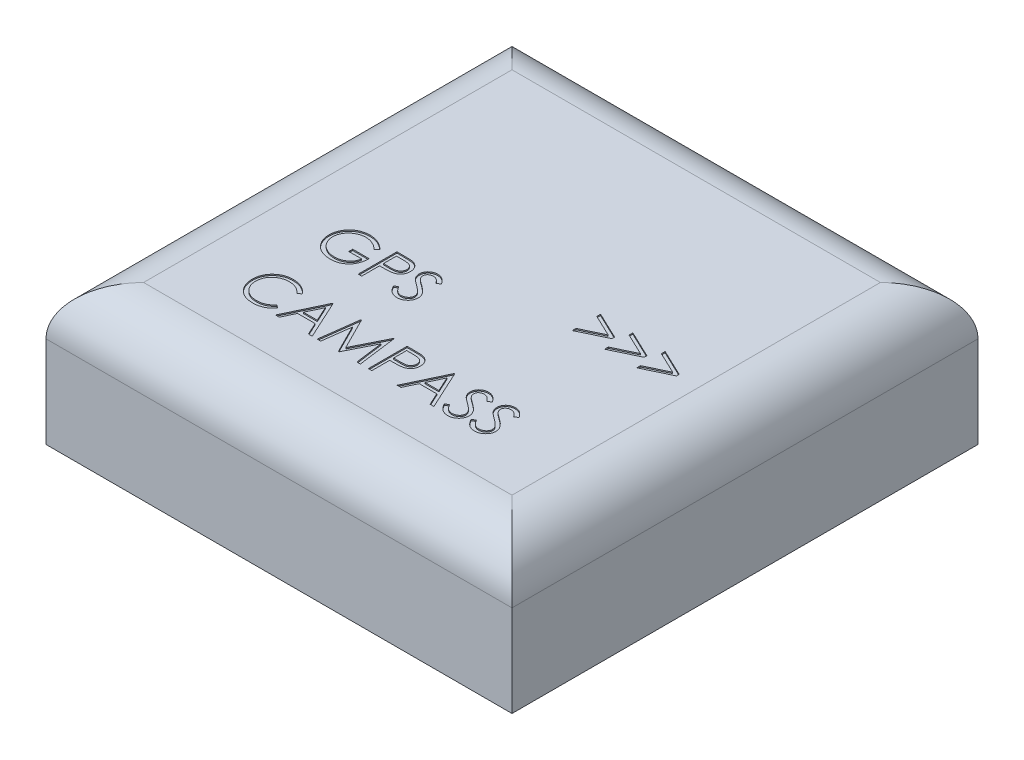
from build123d import *

# Parameters (mm, degrees)
SKETCH2_W           = 38.2
SKETCH2_H           = 38.2
BOSS_EXTRUDE1_DEPTH = 11.5
CUT_EXTRUDE1_DEPTH  = 0.1
FILLET1_R           = 4
SKETCH5_W           = 9.4
SKETCH5_H           = 4
CUT_EXTRUDE2_DEPTH  = 3


with BuildPart() as part:
    # Sketch2 → Boss-Extrude1 (new body)
    with BuildSketch(Plane(origin=(0, 0, 0), x_dir=(1, 0, 0), z_dir=(0, 1, 0))):
        Rectangle(SKETCH2_W, SKETCH2_H)
    extrude(amount=BOSS_EXTRUDE1_DEPTH)

    # Sketch4 → Cut-Extrude1 (cut)
    with BuildSketch(Plane(origin=(0, 11.5, 0), x_dir=(1, 0, 0), z_dir=(0, 1, 0))):
        Polygon((5.884704752, -0.633123186), (7.666826146, 0.217232383), (5.884704752, 1.067587952), (5.884704752, 1.377328537), (8.082781675, 0.328535468), (8.082781675, 0.105929298), (5.884704752, -0.942863771), align=None)
        Polygon((8.530538085, -0.633123186), (10.312659479, 0.217232383), (8.530538085, 1.067587952), (8.530538085, 1.377328537), (10.728615008, 0.328535468), (10.728615008, 0.105929298), (8.530538085, -0.942863771), align=None)
        Polygon((11.176371418, -0.633123186), (12.958492813, 0.217232383), (11.176371418, 1.067587952), (11.176371418, 1.377328537), (13.374448341, 0.328535468), (13.374448341, 0.105929298), (11.176371418, -0.942863771), align=None)
        with BuildLine():
            Line((-7.751098915, -3.078066088), (-7.995329685, -3.309576505))
            add(Edge.make_bspline(
                [(-7.995329685, -3.309576505), (-8.039524676, -3.268001365), (-8.126860804, -3.185842468), (-8.269246167, -3.079243208), (-8.417803178, -2.987924674), (-8.571756657, -2.913624017), (-8.72729406, -2.854339727), (-8.882350878, -2.812132057), (-9.035336621, -2.785214827), (-9.137088312, -2.781995949), (-9.18722672, -2.780409838)],
                knots=[0, 0, 0, 0, 0.000181914, 0.000359491, 0.000532492, 0.000704303, 0.000871571, 0.001031109, 0.001185858, 0.001336186, 0.001336186, 0.001336186, 0.001336186], degree=3))
            add(Edge.make_bspline(
                [(-9.18722672, -2.780409838), (-9.217992198, -2.780785038), (-9.279443362, -2.781534464), (-9.370721839, -2.791099574), (-9.461043003, -2.804856272), (-9.55023635, -2.824760689), (-9.638475303, -2.849987479), (-9.725452969, -2.881542863), (-9.811331598, -2.918332264), (-9.895302257, -2.960843222), (-9.976709714, -3.007542797), (-10.053596272, -3.059293973), (-10.126451998, -3.11443809), (-10.193907527, -3.174355764), (-10.256350875, -3.238504249), (-10.315268327, -3.305690248), (-10.368587731, -3.377749339), (-10.416749002, -3.453355728), (-10.459712756, -3.5311815), (-10.497639177, -3.610477569), (-10.52947725, -3.690980923), (-10.554668113, -3.772792579), (-10.575451349, -3.855279614), (-10.590072321, -3.939013182), (-10.598315276, -4.024082939), (-10.599741105, -4.081049024), (-10.60045789, -4.109686681)],
                knots=[0, 0, 0, 0, 9.2258e-05, 0.000184276, 0.00027504, 0.000366239, 0.000458233, 0.000550174, 0.000643626, 0.000738343, 0.000832379, 0.000924989, 0.001016197, 0.001106306, 0.001195357, 0.001284626, 0.001374178, 0.001463983, 0.001553373, 0.001640711, 0.00172752, 0.001812813, 0.001897346, 0.001982565, 0.002067558, 0.002153479, 0.002153479, 0.002153479, 0.002153479], degree=3))
            add(Edge.make_bspline(
                [(-10.60045789, -4.109686681), (-10.599772345, -4.138960922), (-10.598403128, -4.197429467), (-10.589639839, -4.284691233), (-10.573376363, -4.370656991), (-10.551634227, -4.455609226), (-10.524437345, -4.539693429), (-10.490534998, -4.622545063), (-10.450379774, -4.704161061), (-10.403900902, -4.783806042), (-10.352931989, -4.861387642), (-10.295833623, -4.934466636), (-10.235181522, -5.00401617), (-10.168766056, -5.068492042), (-10.098716899, -5.129618862), (-10.022941192, -5.185712514), (-9.94292896, -5.237853473), (-9.858558132, -5.285384602), (-9.770744179, -5.327846631), (-9.680704125, -5.365605451), (-9.588150321, -5.396701707), (-9.493569166, -5.422045558), (-9.397073413, -5.442819399), (-9.298173249, -5.456183863), (-9.197595863, -5.465881974), (-9.129797247, -5.466591061), (-9.095640181, -5.4669483)],
                knots=[0, 0, 0, 0, 8.7828e-05, 0.000175416, 0.000262738, 0.000350049, 0.000438346, 0.000527635, 0.000618372, 0.000710989, 0.000804128, 0.000896615, 0.000988996, 0.001080745, 0.001174084, 0.001267706, 0.001363321, 0.001460434, 0.001558002, 0.001655802, 0.001753148, 0.001850656, 0.00194945, 0.00204902, 0.002149905, 0.002252335, 0.002252335, 0.002252335, 0.002252335], degree=3))
            add(Edge.make_bspline(
                [(-9.095640181, -5.4669483), (-9.054475538, -5.466087806), (-8.973642072, -5.464398085), (-8.854818656, -5.451244251), (-8.740697299, -5.430700374), (-8.631598672, -5.400614168), (-8.527396061, -5.362238691), (-8.427707464, -5.315978591), (-8.333317745, -5.26005953), (-8.243943152, -5.196946093), (-8.161613419, -5.126629067), (-8.087360035, -5.050751597), (-8.022367341, -4.969681994), (-7.96566665, -4.883897743), (-7.918759513, -4.792688788), (-7.880257835, -4.696502106), (-7.850745492, -4.595294435), (-7.838630622, -4.525361312), (-7.832509172, -4.490025223)],
                knots=[0, 0, 0, 0, 0.000123468, 0.000242449, 0.000358215, 0.000471007, 0.000581478, 0.000691023, 0.000800213, 0.000910155, 0.001018877, 0.001124573, 0.001228173, 0.001330135, 0.001432542, 0.001535293, 0.001640567, 0.00174809, 0.00174809, 0.00174809, 0.00174809], degree=3))
            Line((-7.832509172, -4.490025223), (-8.890842505, -4.490025223))
            Line((-8.890842505, -4.490025223), (-8.890842505, -4.164384197))
            Line((-8.890842505, -4.164384197), (-7.547573274, -4.164384197))
            add(Edge.make_bspline(
                [(-7.547573274, -4.164384197), (-7.549120723, -4.225078848), (-7.552149358, -4.343869243), (-7.57339366, -4.51710656), (-7.607698639, -4.680729453), (-7.654561922, -4.83491024), (-7.715227355, -4.979430427), (-7.789043863, -5.114436749), (-7.877192858, -5.239057023), (-7.976534473, -5.35430862), (-8.088022292, -5.457114405), (-8.208643826, -5.54747122), (-8.338598361, -5.623582878), (-8.477762973, -5.685505051), (-8.62568208, -5.733832175), (-8.782697967, -5.768096391), (-8.948597705, -5.788625), (-9.062295976, -5.791247894), (-9.120444869, -5.792589325)],
                knots=[0, 0, 0, 0, 0.000182061, 0.000356326, 0.00052273, 0.000683073, 0.000838996, 0.000992139, 0.001143712, 0.001296104, 0.001447776, 0.00159775, 0.00174741, 0.001898587, 0.002053859, 0.002213423, 0.002380035, 0.002554445, 0.002554445, 0.002554445, 0.002554445], degree=3))
            add(Edge.make_bspline(
                [(-9.120444869, -5.792589325), (-9.156286206, -5.792073051), (-9.226976874, -5.791054792), (-9.331380788, -5.783818198), (-9.432906058, -5.772677961), (-9.531537894, -5.755854885), (-9.627639105, -5.735249449), (-9.720729728, -5.708863639), (-9.81116438, -5.678321319), (-9.899082838, -5.643581673), (-9.983687106, -5.603330241), (-10.065354018, -5.558599354), (-10.144535003, -5.509619662), (-10.220690703, -5.455544109), (-10.294217916, -5.396777163), (-10.36464254, -5.333201037), (-10.43235883, -5.265010093), (-10.47477725, -5.216587705), (-10.496150999, -5.192188684)],
                knots=[0, 0, 0, 0, 0.000107517, 0.000212058, 0.000313831, 0.000413791, 0.000512097, 0.000608547, 0.000703882, 0.000798366, 0.000891967, 0.000984756, 0.00107759, 0.00117112, 0.001264787, 0.001359809, 0.001455603, 0.001552895, 0.001552895, 0.001552895, 0.001552895], degree=3))
            add(Edge.make_bspline(
                [(-10.496150999, -5.192188684), (-10.527162523, -5.153480306), (-10.588670811, -5.076706069), (-10.667844568, -4.953697548), (-10.735337269, -4.826333004), (-10.790099507, -4.694257877), (-10.832860486, -4.557595705), (-10.863527586, -4.416521119), (-10.881495627, -4.270852454), (-10.884084193, -4.172277536), (-10.885393787, -4.122407034)],
                knots=[0, 0, 0, 0, 0.000148717, 0.000294965, 0.00043807, 0.000580636, 0.000723259, 0.000867096, 0.001013197, 0.001162796, 0.001162796, 0.001162796, 0.001162796], degree=3))
            add(Edge.make_bspline(
                [(-10.885393787, -4.122407034), (-10.884910971, -4.085063362), (-10.883951475, -4.010850633), (-10.8723169, -3.900671504), (-10.855624185, -3.792448733), (-10.831088643, -3.686270786), (-10.80015846, -3.582066749), (-10.761556369, -3.479788239), (-10.71661207, -3.379374898), (-10.664373799, -3.281517889), (-10.606240039, -3.187515743), (-10.543148054, -3.097746879), (-10.474201931, -3.013846084), (-10.400527598, -2.934750803), (-10.321246043, -2.861454706), (-10.237099994, -2.793279192), (-10.148024605, -2.730132809), (-10.053739641, -2.673010173), (-9.955652385, -2.621698889), (-9.853997955, -2.57671439), (-9.748807383, -2.539536668), (-9.640868742, -2.507991882), (-9.52936501, -2.484664576), (-9.415105344, -2.4677475), (-9.297494171, -2.456171813), (-9.217995773, -2.455240852), (-9.177686455, -2.454768813)],
                knots=[0, 0, 0, 0, 0.000111984, 0.000222545, 0.000332023, 0.000440333, 0.000549196, 0.000657879, 0.00076805, 0.000879016, 0.000990392, 0.001099448, 0.001207922, 0.001315918, 0.00142348, 0.001531553, 0.001640609, 0.001750778, 0.00186201, 0.001972503, 0.002083953, 0.002196478, 0.00230962, 0.002425384, 0.002542909, 0.002663794, 0.002663794, 0.002663794, 0.002663794], degree=3))
            add(Edge.make_bspline(
                [(-9.177686455, -2.454768813), (-9.144813192, -2.455294494), (-9.079629372, -2.45633686), (-8.982632458, -2.463561933), (-8.887134795, -2.475013597), (-8.792994784, -2.490640753), (-8.700533009, -2.511925672), (-8.609486069, -2.537396688), (-8.519721982, -2.567052841), (-8.431522071, -2.602421295), (-8.344293285, -2.642565654), (-8.257550616, -2.687753545), (-8.171590443, -2.738757656), (-8.086263695, -2.795729435), (-8.00103231, -2.857690392), (-7.917244384, -2.926412654), (-7.832877428, -2.999186154), (-7.778628639, -3.051512135), (-7.751098915, -3.078066088)],
                knots=[0, 0, 0, 0, 9.8616e-05, 0.000195543, 0.00029163, 0.000387094, 0.000481675, 0.000576117, 0.000670646, 0.000765131, 0.000861036, 0.000958613, 0.001058419, 0.001160731, 0.001266317, 0.00137439, 0.001485737, 0.001600462, 0.001600462, 0.001600462, 0.001600462], degree=3))
        make_face()
        with BuildLine():
            Line((-6.896291223, -2.536179069), (-6.273629965, -2.536179069))
            add(Edge.make_bspline(
                [(-6.273629965, -2.536179069), (-6.230802929, -2.536226146), (-6.148744425, -2.536316348), (-6.031074339, -2.539051154), (-5.924204083, -2.542703939), (-5.828364094, -2.547767513), (-5.743259491, -2.553751563), (-5.669275369, -2.562144484), (-5.6058302, -2.570907752), (-5.567815064, -2.579817171), (-5.550477922, -2.583880391)],
                knots=[0, 0, 0, 0, 0.000128477, 0.000246168, 0.000353087, 0.00044926, 0.000534089, 0.000608961, 0.000672646, 0.000726041, 0.000726041, 0.000726041, 0.000726041], degree=3))
            add(Edge.make_bspline(
                [(-5.550477922, -2.583880391), (-5.52853093, -2.589887446), (-5.485154101, -2.601760006), (-5.422651012, -2.625539598), (-5.363184309, -2.653735562), (-5.306549967, -2.685870136), (-5.253443935, -2.723322041), (-5.203073883, -2.764573108), (-5.15588433, -2.810575745), (-5.112140638, -2.860813988), (-5.071968001, -2.914444464), (-5.037378931, -2.972267773), (-5.008416375, -3.033310598), (-4.983575836, -3.09753048), (-4.965697452, -3.165466702), (-4.952229193, -3.23664722), (-4.943680617, -3.311064403), (-4.942861864, -3.361918712), (-4.942445069, -3.387806673)],
                knots=[0, 0, 0, 0, 6.8232e-05, 0.000134856, 0.000200292, 0.000265532, 0.000329934, 0.000395001, 0.000460668, 0.00052738, 0.000594672, 0.000661426, 0.000729131, 0.00079717, 0.00086768, 0.00093953, 0.001014402, 0.001092038, 0.001092038, 0.001092038, 0.001092038], degree=3))
            add(Edge.make_bspline(
                [(-4.942445069, -3.387806673), (-4.942827362, -3.413912228), (-4.943575343, -3.464989509), (-4.952552687, -3.539713395), (-4.964645075, -3.61112222), (-4.98323883, -3.67905765), (-5.007591691, -3.743116242), (-5.036159481, -3.804276931), (-5.07061597, -3.861499205), (-5.110208065, -3.914990805), (-5.154251297, -3.964801939), (-5.20255932, -4.010571646), (-5.254937106, -4.05203201), (-5.311218198, -4.089275979), (-5.371951275, -4.12143989), (-5.436215229, -4.150248302), (-5.504568639, -4.174442764), (-5.551869348, -4.187170034), (-5.575918627, -4.193641008)],
                knots=[0, 0, 0, 0, 7.8272e-05, 0.000153144, 0.000225504, 0.0002954, 0.000364034, 0.000430891, 0.000497646, 0.000564048, 0.000630282, 0.000696867, 0.000763418, 0.000830451, 0.000899029, 0.000969354, 0.001041572, 0.001116269, 0.001116269, 0.001116269, 0.001116269], degree=3))
            add(Edge.make_bspline(
                [(-5.575918627, -4.193641008), (-5.595809851, -4.197870998), (-5.639402626, -4.207141267), (-5.711196381, -4.217490367), (-5.79478541, -4.226323762), (-5.890055621, -4.232946937), (-5.996921499, -4.238616914), (-6.115440854, -4.243123685), (-6.245846338, -4.245600052), (-6.336806681, -4.245727771), (-6.384297032, -4.245794454)],
                knots=[0, 0, 0, 0, 6.0995e-05, 0.000133673, 0.000217466, 0.000313125, 0.000420129, 0.000538512, 0.000668921, 0.00081139, 0.00081139, 0.00081139, 0.00081139], degree=3))
            Line((-6.384297032, -4.245794454), (-6.611355326, -4.245794454))
            Line((-6.611355326, -4.245794454), (-6.611355326, -5.711179069))
            Line((-6.611355326, -5.711179069), (-6.896291223, -5.711179069))
            Line((-6.896291223, -5.711179069), (-6.896291223, -2.536179069))
        make_face()
        with BuildLine():
            Line((-6.611355326, -2.861820095), (-6.611355326, -3.920153428))
            Line((-6.611355326, -3.920153428), (-6.055475919, -3.927149622))
            add(Edge.make_bspline(
                [(-6.055475919, -3.927149622), (-6.028334272, -3.92716365), (-5.975937882, -3.92719073), (-5.900249308, -3.923575563), (-5.830028026, -3.919402222), (-5.765489732, -3.913291777), (-5.706605335, -3.904654637), (-5.653276648, -3.895935417), (-5.605917184, -3.883321267), (-5.550491479, -3.866336769), (-5.488730157, -3.837369324), (-5.42154031, -3.795323353), (-5.36459842, -3.74172871), (-5.315323966, -3.681469178), (-5.276220776, -3.61443211), (-5.247594983, -3.542705289), (-5.230775505, -3.467024311), (-5.228520172, -3.415237214), (-5.227380967, -3.389078708)],
                knots=[0, 0, 0, 0, 8.1413e-05, 0.000157166, 0.000227269, 0.000292454, 0.000351549, 0.000405819, 0.000454411, 0.000498462, 0.000579576, 0.00065826, 0.000735229, 0.000813005, 0.000891109, 0.000967051, 0.001043901, 0.00112234, 0.00112234, 0.00112234, 0.00112234], degree=3))
            add(Edge.make_bspline(
                [(-5.227380967, -3.389078708), (-5.228526367, -3.363553057), (-5.230803282, -3.312811221), (-5.247726815, -3.238444774), (-5.276165122, -3.167473813), (-5.315586461, -3.1012768), (-5.3634302, -3.0412341), (-5.419037461, -2.989075991), (-5.482277348, -2.947146304), (-5.541103958, -2.920083256), (-5.593356463, -2.903559399), (-5.638742598, -2.891998008), (-5.689987709, -2.882767279), (-5.747108481, -2.875292873), (-5.80966218, -2.868894376), (-5.878186223, -2.864552811), (-5.952421028, -2.86201149), (-6.003956331, -2.861885438), (-6.030671231, -2.861820095)],
                knots=[0, 0, 0, 0, 7.6536e-05, 0.000152145, 0.000227496, 0.000305051, 0.000382429, 0.000457133, 0.000532809, 0.00060908, 0.000650514, 0.0006971, 0.000749494, 0.000806611, 0.000869897, 0.000938097, 0.001012554, 0.001092695, 0.001092695, 0.001092695, 0.001092695], degree=3))
            Line((-6.030671231, -2.861820095), (-6.611355326, -2.861820095))
        make_face(mode=Mode.SUBTRACT)
        with BuildLine():
            Line((-4.616804044, -5.098694093), (-4.348404604, -4.937781633))
            add(Edge.make_bspline(
                [(-4.348404604, -4.937781633), (-4.323441632, -4.979568611), (-4.27561354, -5.059630848), (-4.195829093, -5.167814927), (-4.113158524, -5.259764884), (-4.026989628, -5.334945806), (-3.937848375, -5.394135868), (-3.845152841, -5.436047892), (-3.749215398, -5.462188099), (-3.68392486, -5.465363177), (-3.651329284, -5.4669483)],
                knots=[0, 0, 0, 0, 0.00014596, 0.000279654, 0.00040257, 0.000516191, 0.000621858, 0.000722343, 0.000820302, 0.000917964, 0.000917964, 0.000917964, 0.000917964], degree=3))
            add(Edge.make_bspline(
                [(-3.651329284, -5.4669483), (-3.623491918, -5.46617299), (-3.568304274, -5.464635936), (-3.487058525, -5.449866922), (-3.408153604, -5.427177348), (-3.333215768, -5.394682646), (-3.263279032, -5.355368448), (-3.201950101, -5.307882987), (-3.148931127, -5.254718786), (-3.105561431, -5.195407378), (-3.072287399, -5.131619679), (-3.046713165, -5.06614578), (-3.032520848, -4.997957151), (-3.030382936, -4.952046231), (-3.029304044, -4.928877386)],
                knots=[0, 0, 0, 0, 8.3437e-05, 0.000165414, 0.000246926, 0.00032927, 0.000409894, 0.000486986, 0.000561194, 0.000634468, 0.000706451, 0.000776499, 0.000844731, 0.000914244, 0.000914244, 0.000914244, 0.000914244], degree=3))
            add(Edge.make_bspline(
                [(-3.029304044, -4.928877386), (-3.030641454, -4.902442473), (-3.033360214, -4.848704156), (-3.056339485, -4.769420185), (-3.092488445, -4.690959068), (-3.125837414, -4.642425777), (-3.143151199, -4.617228748)],
                knots=[0, 0, 0, 0, 7.9176e-05, 0.000160953, 0.000245754, 0.000337316, 0.000337316, 0.000337316, 0.000337316], degree=3))
            add(Edge.make_bspline(
                [(-3.143151199, -4.617228748), (-3.157366685, -4.599043416), (-3.187210319, -4.560865584), (-3.238516062, -4.504037406), (-3.298719609, -4.445419269), (-3.365760691, -4.382772839), (-3.442081422, -4.319011766), (-3.525291381, -4.251095542), (-3.617515025, -4.181606969), (-3.682193854, -4.135004713), (-3.715567064, -4.110958716)],
                knots=[0, 0, 0, 0, 6.9232e-05, 0.000145345, 0.000229446, 0.000321262, 0.000420534, 0.000527712, 0.000643469, 0.000766871, 0.000766871, 0.000766871, 0.000766871], degree=3))
            add(Edge.make_bspline(
                [(-3.715567064, -4.110958716), (-3.74897169, -4.087165641), (-3.812838789, -4.041675091), (-3.902154789, -3.974161634), (-3.982023694, -3.912436123), (-4.052090517, -3.855917484), (-4.112324437, -3.804598049), (-4.163200102, -3.758970633), (-4.203421508, -3.71780126), (-4.225787642, -3.691093757), (-4.235829484, -3.679102747)],
                knots=[0, 0, 0, 0, 0.00012303, 0.000235223, 0.000335855, 0.000425848, 0.000505251, 0.000573234, 0.000630807, 0.000677717, 0.000677717, 0.000677717, 0.000677717], degree=3))
            add(Edge.make_bspline(
                [(-4.235829484, -3.679102747), (-4.249865293, -3.660414663), (-4.277468595, -3.623662039), (-4.3139049, -3.566217347), (-4.344873998, -3.507413385), (-4.369151256, -3.447092136), (-4.389594826, -3.386100451), (-4.403345235, -3.323642535), (-4.411955288, -3.259998645), (-4.412837018, -3.217169255), (-4.413278403, -3.195729349)],
                knots=[0, 0, 0, 0, 7.0095e-05, 0.000137851, 0.00020385, 0.000269165, 0.000332722, 0.000396603, 0.00046074, 0.000525028, 0.000525028, 0.000525028, 0.000525028], degree=3))
            add(Edge.make_bspline(
                [(-4.413278403, -3.195729349), (-4.412094392, -3.162138054), (-4.409751677, -3.095673453), (-4.389939208, -2.9985812), (-4.358667368, -2.905883521), (-4.314857006, -2.818498147), (-4.258380693, -2.738700436), (-4.193024702, -2.665572487), (-4.115181425, -2.604096702), (-4.029771545, -2.550382906), (-3.936284694, -2.508340531), (-3.838321517, -2.476625928), (-3.735726316, -2.458656101), (-3.666236329, -2.456077307), (-3.63097672, -2.454768813)],
                knots=[0, 0, 0, 0, 0.000100692, 0.000199231, 0.000295975, 0.000393537, 0.000491285, 0.000588532, 0.00068667, 0.000787797, 0.000890545, 0.00099333, 0.001096013, 0.001201783, 0.001201783, 0.001201783, 0.001201783], degree=3))
            add(Edge.make_bspline(
                [(-3.63097672, -2.454768813), (-3.593562429, -2.45605927), (-3.519157346, -2.458625578), (-3.409711271, -2.480939053), (-3.304336907, -2.517860377), (-3.219570517, -2.559760088), (-3.153228655, -2.601607872), (-3.102634819, -2.639725856), (-3.051365417, -2.68360899), (-2.999006896, -2.733374163), (-2.94644644, -2.789478002), (-2.892903737, -2.851536269), (-2.838253579, -2.919169716), (-2.803096478, -2.967451942), (-2.785073274, -2.992203708)],
                knots=[0, 0, 0, 0, 0.000112158, 0.000223046, 0.000333473, 0.000446394, 0.000505858, 0.000568569, 0.000636244, 0.000708224, 0.000785161, 0.000866773, 0.000954083, 0.001045926, 0.001045926, 0.001045926, 0.001045926], degree=3))
            Line((-2.785073274, -2.992203708), (-3.042660414, -3.18746112))
            add(Edge.make_bspline(
                [(-3.042660414, -3.18746112), (-3.058214224, -3.167423523), (-3.088167226, -3.128835794), (-3.133641832, -3.074796101), (-3.176503105, -3.02543258), (-3.218730968, -2.982556357), (-3.258095191, -2.943819422), (-3.296301365, -2.910654499), (-3.332799669, -2.882736638), (-3.378807152, -2.852942837), (-3.436608225, -2.823409437), (-3.509165626, -2.798418488), (-3.584990318, -2.783400682), (-3.636633627, -2.781415048), (-3.662777601, -2.780409838)],
                knots=[0, 0, 0, 0, 7.6089e-05, 0.000146529, 0.000211865, 0.000272136, 0.000327011, 0.000377509, 0.000423812, 0.00046474, 0.000541824, 0.000617855, 0.000694317, 0.000772712, 0.000772712, 0.000772712, 0.000772712], degree=3))
            add(Edge.make_bspline(
                [(-3.662777601, -2.780409838), (-3.695576732, -2.781509023), (-3.758826767, -2.783628698), (-3.848625052, -2.80677897), (-3.92944597, -2.843229658), (-3.998890083, -2.894315388), (-4.056708626, -2.95484086), (-4.098532864, -3.02449025), (-4.123706227, -3.101400001), (-4.126778067, -3.155049932), (-4.128342505, -3.182372979)],
                knots=[0, 0, 0, 0, 9.8196e-05, 0.000189362, 0.000276162, 0.00036267, 0.000446363, 0.000525662, 0.000604507, 0.000686336, 0.000686336, 0.000686336, 0.000686336], degree=3))
            add(Edge.make_bspline(
                [(-4.128342505, -3.182372979), (-4.127985883, -3.199383249), (-4.127272056, -3.233431604), (-4.117316347, -3.283733965), (-4.104526241, -3.333909252), (-4.084258282, -3.38373188), (-4.056277185, -3.434073192), (-4.019533204, -3.485800054), (-3.973256843, -3.539368389), (-3.93780841, -3.574209364), (-3.919092705, -3.592604349)],
                knots=[0, 0, 0, 0, 5.0945e-05, 0.000101973, 0.000153349, 0.000206142, 0.000262791, 0.000325786, 0.000396151, 0.000474855, 0.000474855, 0.000474855, 0.000474855], degree=3))
            add(Edge.make_bspline(
                [(-3.919092705, -3.592604349), (-3.912142746, -3.598806509), (-3.895631234, -3.613541419), (-3.865445216, -3.637664416), (-3.82558282, -3.667421217), (-3.777084966, -3.704239711), (-3.719057431, -3.746949323), (-3.651493833, -3.795003957), (-3.5751473, -3.849963624), (-3.520970991, -3.888387964), (-3.492324877, -3.908705111)],
                knots=[0, 0, 0, 0, 2.7941e-05, 6.6382e-05, 0.000115865, 0.000177177, 0.00024905, 0.000332006, 0.000425904, 0.000531263, 0.000531263, 0.000531263, 0.000531263], degree=3))
            add(Edge.make_bspline(
                [(-3.492324877, -3.908705111), (-3.457866227, -3.933779773), (-3.391141827, -3.98233338), (-3.296202451, -4.05528189), (-3.210120211, -4.126626651), (-3.132592876, -4.195912052), (-3.062854538, -4.262612536), (-3.001678891, -4.327530564), (-2.948442596, -4.390201048), (-2.891130019, -4.470549027), (-2.832566854, -4.569229011), (-2.782273487, -4.690131413), (-2.750561271, -4.811503789), (-2.746414254, -4.893080277), (-2.744368146, -4.93332951)],
                knots=[0, 0, 0, 0, 0.000127846, 0.000247556, 0.00035912, 0.000463173, 0.000559432, 0.00064852, 0.000730687, 0.00080588, 0.000944415, 0.001073869, 0.001197738, 0.001318375, 0.001318375, 0.001318375, 0.001318375], degree=3))
            add(Edge.make_bspline(
                [(-2.744368146, -4.93332951), (-2.744964264, -4.961794169), (-2.746144924, -5.018170725), (-2.75971661, -5.100952116), (-2.779600878, -5.181352976), (-2.809570369, -5.258379485), (-2.846149234, -5.333440806), (-2.89256433, -5.404567972), (-2.946364873, -5.473335205), (-3.008081217, -5.537908801), (-3.075614285, -5.597187136), (-3.146991637, -5.649918499), (-3.222330099, -5.693886192), (-3.301220972, -5.729764456), (-3.383682377, -5.757825576), (-3.469686581, -5.77815725), (-3.559375352, -5.790635645), (-3.620335789, -5.791930828), (-3.651329284, -5.792589325)],
                knots=[0, 0, 0, 0, 8.5312e-05, 0.000168967, 0.000251033, 0.000333365, 0.00041642, 0.000501104, 0.000587623, 0.000678047, 0.000768632, 0.000856918, 0.000943857, 0.001029813, 0.001116501, 0.001204743, 0.001294601, 0.001387538, 0.001387538, 0.001387538, 0.001387538], degree=3))
            add(Edge.make_bspline(
                [(-3.651329284, -5.792589325), (-3.675309917, -5.792125611), (-3.72296917, -5.791204021), (-3.793462772, -5.783056717), (-3.862532256, -5.771529559), (-3.929310926, -5.753228795), (-3.99465915, -5.73102468), (-4.058292713, -5.703684907), (-4.120242454, -5.670921446), (-4.180855547, -5.633460959), (-4.239977834, -5.589865719), (-4.29705478, -5.539089762), (-4.353959113, -5.482533482), (-4.409011251, -5.418661043), (-4.463324746, -5.348504353), (-4.515828732, -5.271407023), (-4.567610004, -5.187788995), (-4.60009975, -5.128947095), (-4.616804044, -5.098694093)],
                knots=[0, 0, 0, 0, 7.1915e-05, 0.000142924, 0.000212669, 0.000281785, 0.000350371, 0.000419604, 0.000489305, 0.000560431, 0.000633193, 0.000709359, 0.000789411, 0.000873714, 0.00096213, 0.001055453, 0.001153412, 0.001257074, 0.001257074, 0.001257074, 0.001257074], degree=3))
        make_face()
        with BuildLine():
            Line((-7.791804044, -9.410437883), (-8.041122954, -9.601243172))
            add(Edge.make_bspline(
                [(-8.041122954, -9.601243172), (-8.058908295, -9.580046899), (-8.094239194, -9.537940125), (-8.151080042, -9.478812967), (-8.210317961, -9.423418051), (-8.271930306, -9.371491489), (-8.337026079, -9.324849137), (-8.404028375, -9.281060351), (-8.47405803, -9.241810332), (-8.570897104, -9.194218909), (-8.697577652, -9.144556325), (-8.857048684, -9.102915537), (-9.023519467, -9.076407756), (-9.137091575, -9.073536793), (-9.194858931, -9.072076505)],
                knots=[0, 0, 0, 0, 8.299e-05, 0.000164861, 0.000245858, 0.000326233, 0.000406381, 0.000485944, 0.000566254, 0.000647036, 0.000809554, 0.000973391, 0.001140702, 0.001313896, 0.001313896, 0.001313896, 0.001313896], degree=3))
            add(Edge.make_bspline(
                [(-9.194858931, -9.072076505), (-9.226684496, -9.072442957), (-9.290040253, -9.073172459), (-9.384064226, -9.082796451), (-9.476332494, -9.096323049), (-9.566785038, -9.116393878), (-9.655306722, -9.141769039), (-9.742476258, -9.172090665), (-9.827031588, -9.209605412), (-9.910142418, -9.251069334), (-9.989770702, -9.297902802), (-10.065113496, -9.348987057), (-10.135896009, -9.403750451), (-10.202174236, -9.462398241), (-10.264015932, -9.524666305), (-10.320972993, -9.591218243), (-10.372848329, -9.661841286), (-10.420670202, -9.735604163), (-10.463498896, -9.812292017), (-10.499358143, -9.892188688), (-10.53111279, -9.973925981), (-10.55623996, -10.058427392), (-10.576128629, -10.145098329), (-10.589851581, -10.234171401), (-10.599366122, -10.325460525), (-10.600091997, -10.387336116), (-10.60045789, -10.418525824)],
                knots=[0, 0, 0, 0, 9.5437e-05, 0.000189987, 0.000283265, 0.000375086, 0.000467691, 0.000559419, 0.000651703, 0.000744998, 0.000837935, 0.000928607, 0.001017915, 0.001106228, 0.001193927, 0.001280987, 0.00136876, 0.001456615, 0.001544584, 0.001631962, 0.001719133, 0.001807466, 0.001896183, 0.00198569, 0.002077709, 0.002171238, 0.002171238, 0.002171238, 0.002171238], degree=3))
            add(Edge.make_bspline(
                [(-10.60045789, -10.418525824), (-10.59931324, -10.465453521), (-10.597065871, -10.55758983), (-10.577064882, -10.692546027), (-10.546670978, -10.821832638), (-10.501118276, -10.944641495), (-10.444948852, -11.062486934), (-10.37397344, -11.173375037), (-10.291771295, -11.278981492), (-10.1971795, -11.376810452), (-10.093397082, -11.466176474), (-9.98204719, -11.544871644), (-9.863407158, -11.610471573), (-9.738786929, -11.665059753), (-9.607227526, -11.707021213), (-9.468965526, -11.736561526), (-9.324301645, -11.755831218), (-9.225450832, -11.757676063), (-9.175142385, -11.758614966)],
                knots=[0, 0, 0, 0, 0.000140704, 0.000276253, 0.000408455, 0.000538433, 0.000668431, 0.000799358, 0.000932567, 0.001069312, 0.00120687, 0.001342915, 0.001477586, 0.00161288, 0.00175046, 0.001891054, 0.002036604, 0.002187448, 0.002187448, 0.002187448, 0.002187448], degree=3))
            add(Edge.make_bspline(
                [(-9.175142385, -11.758614966), (-9.119713517, -11.757083002), (-9.010616245, -11.754067729), (-8.85062525, -11.728523268), (-8.697467091, -11.687105014), (-8.551133531, -11.62914047), (-8.412037102, -11.553788387), (-8.279960131, -11.462441027), (-8.154791135, -11.354229468), (-8.079524329, -11.271604059), (-8.041122954, -11.2294483)],
                knots=[0, 0, 0, 0, 0.000166206, 0.000327134, 0.000484664, 0.00064139, 0.000798189, 0.000958205, 0.001122325, 0.001293282, 0.001293282, 0.001293282, 0.001293282], degree=3))
            Line((-8.041122954, -11.2294483), (-7.791804044, -11.418345535))
            add(Edge.make_bspline(
                [(-7.791804044, -11.418345535), (-7.811868329, -11.444233988), (-7.851900793, -11.49588689), (-7.916723423, -11.568704798), (-7.985010685, -11.637197744), (-8.057269794, -11.700813515), (-8.132669505, -11.760825066), (-8.212563674, -11.815527441), (-8.29590201, -11.865684172), (-8.382402145, -11.911610025), (-8.471972172, -11.952356385), (-8.564504767, -11.987239446), (-8.659601074, -12.017288452), (-8.757265443, -12.042009852), (-8.857700451, -12.061305764), (-8.960543667, -12.07420504), (-9.066017053, -12.083042349), (-9.137174628, -12.083847815), (-9.173234332, -12.084255992)],
                knots=[0, 0, 0, 0, 9.8237e-05, 0.000196004, 0.000292247, 0.000388218, 0.000484669, 0.00058117, 0.000678466, 0.000776338, 0.000874822, 0.000973456, 0.001072826, 0.001173865, 0.001275526, 0.001379423, 0.001484691, 0.001592844, 0.001592844, 0.001592844, 0.001592844], degree=3))
            add(Edge.make_bspline(
                [(-9.173234332, -12.084255992), (-9.207382516, -12.084018327), (-9.27490632, -12.083548375), (-9.374600188, -12.07593548), (-9.471655022, -12.065548933), (-9.565793432, -12.049909671), (-9.657529138, -12.031454449), (-9.746030526, -12.006715523), (-9.832168467, -11.979003065), (-9.91559689, -11.946432112), (-9.99638676, -11.909678147), (-10.074277504, -11.868138661), (-10.149233296, -11.82216297), (-10.221991071, -11.772764496), (-10.291476021, -11.718356515), (-10.358290291, -11.659694639), (-10.422808537, -11.596976587), (-10.462725259, -11.551751113), (-10.482794629, -11.529012603)],
                knots=[0, 0, 0, 0, 0.000102417, 0.000202516, 0.000299794, 0.000395154, 0.000488707, 0.000580357, 0.000670665, 0.000760075, 0.000848874, 0.000936794, 0.001024712, 0.001112565, 0.001200478, 0.001289268, 0.001379219, 0.001470177, 0.001470177, 0.001470177, 0.001470177], degree=3))
            add(Edge.make_bspline(
                [(-10.482794629, -11.529012603), (-10.514939819, -11.489514524), (-10.578842116, -11.410995223), (-10.660598986, -11.283735797), (-10.73058284, -11.150868207), (-10.787166711, -11.011694415), (-10.831401476, -10.866526713), (-10.862045846, -10.715291925), (-10.881959087, -10.558131292), (-10.884236278, -10.451236491), (-10.885393787, -10.396901224)],
                knots=[0, 0, 0, 0, 0.000152677, 0.000303511, 0.000452867, 0.000602629, 0.000753527, 0.000907451, 0.001065071, 0.001228016, 0.001228016, 0.001228016, 0.001228016], degree=3))
            add(Edge.make_bspline(
                [(-10.885393787, -10.396901224), (-10.883983004, -10.339791634), (-10.881207378, -10.227432081), (-10.857625477, -10.062537138), (-10.819689855, -9.904556941), (-10.765808392, -9.753786401), (-10.69749568, -9.609432504), (-10.613107252, -9.472597982), (-10.513623487, -9.342407743), (-10.399824622, -9.220837218), (-10.275031397, -9.10967652), (-10.141392187, -9.011880892), (-9.999168564, -8.930494288), (-9.84992737, -8.862462055), (-9.692551073, -8.810170292), (-9.527375445, -8.773564187), (-9.354710858, -8.750779374), (-9.236907086, -8.747899007), (-9.177050438, -8.746435479)],
                knots=[0, 0, 0, 0, 0.000171259, 0.000336941, 0.000498606, 0.000657931, 0.000816392, 0.000976852, 0.001139297, 0.001307149, 0.001475639, 0.001640004, 0.001802988, 0.001966374, 0.002131298, 0.002299486, 0.002473278, 0.002652798, 0.002652798, 0.002652798, 0.002652798], degree=3))
            add(Edge.make_bspline(
                [(-9.177050438, -8.746435479), (-9.140570167, -8.746872847), (-9.068361144, -8.747738574), (-8.961542667, -8.756180574), (-8.857545699, -8.770253631), (-8.756298594, -8.789408923), (-8.657308792, -8.813182708), (-8.561332859, -8.844152835), (-8.467807622, -8.879564546), (-8.377322926, -8.920348297), (-8.290312913, -8.966128841), (-8.206804681, -9.016398728), (-8.127461559, -9.071095637), (-8.051725247, -9.129754375), (-7.980862684, -9.193615925), (-7.912861914, -9.260923745), (-7.850032222, -9.333616571), (-7.811248966, -9.384783904), (-7.791804044, -9.410437883)],
                knots=[0, 0, 0, 0, 0.000109425, 0.000216595, 0.000321206, 0.000424117, 0.000525619, 0.000626393, 0.000726442, 0.000825506, 0.000923941, 0.001021237, 0.001117738, 0.001212903, 0.001308399, 0.001403742, 0.001499772, 0.001596332, 0.001596332, 0.001596332, 0.001596332], degree=3))
        make_face()
        Polygon((-5.83795789, -8.827845736), (-4.372573274, -12.002845736), (-4.682313859, -12.002845736), (-5.151694869, -10.985217531), (-6.591002762, -10.985217531), (-7.073740141, -12.002845736), (-7.384752762, -12.002845736), (-5.878663018, -8.827845736), align=None)
        Polygon((-5.861490542, -9.446690888), (-6.436450478, -10.659576505), (-5.301795029, -10.659576505), align=None, mode=Mode.SUBTRACT)
        Polygon((-3.965521992, -12.002845736), (-3.546386375, -8.827845736), (-3.505681247, -8.827845736), (-2.194848915, -11.432973941), (-0.887196672, -8.827845736), (-0.845855526, -8.827845736), (-0.424175838, -12.002845736), (-0.710383771, -12.002845736), (-1.014400197, -9.718270415), (-2.160503963, -12.002845736), (-2.224741744, -12.002845736), (-3.375297633, -9.713182274), (-3.678678042, -12.002845736), align=None)
        with BuildLine():
            Line((0.227106213, -8.827845736), (0.849767471, -8.827845736))
            add(Edge.make_bspline(
                [(0.849767471, -8.827845736), (0.892594507, -8.827892813), (0.974653011, -8.827983015), (1.092323097, -8.83071782), (1.199193353, -8.834370605), (1.295033342, -8.83943418), (1.380137945, -8.84541823), (1.454122067, -8.853811151), (1.517567236, -8.862574419), (1.555582372, -8.871483838), (1.572919514, -8.875547058)],
                knots=[0, 0, 0, 0, 0.000128477, 0.000246168, 0.000353087, 0.00044926, 0.000534089, 0.000608961, 0.000672646, 0.000726041, 0.000726041, 0.000726041, 0.000726041], degree=3))
            add(Edge.make_bspline(
                [(1.572919514, -8.875547058), (1.594866505, -8.881554112), (1.638243335, -8.893426673), (1.700746424, -8.917206265), (1.760213127, -8.945402229), (1.816847469, -8.977536803), (1.869953501, -9.014988707), (1.920323553, -9.056239775), (1.967513106, -9.102242412), (2.011256798, -9.152480655), (2.051429435, -9.206111131), (2.086018505, -9.263934439), (2.114981061, -9.324977265), (2.1398216, -9.389197147), (2.157699984, -9.457133369), (2.171168243, -9.528313887), (2.179716819, -9.60273107), (2.180535571, -9.653585378), (2.180952367, -9.67947334)],
                knots=[0, 0, 0, 0, 6.8232e-05, 0.000134856, 0.000200292, 0.000265532, 0.000329934, 0.000395001, 0.000460668, 0.00052738, 0.000594672, 0.000661426, 0.000729131, 0.00079717, 0.00086768, 0.00093953, 0.001014402, 0.001092038, 0.001092038, 0.001092038, 0.001092038], degree=3))
            add(Edge.make_bspline(
                [(2.180952367, -9.67947334), (2.180570074, -9.705578894), (2.179822093, -9.756656175), (2.170844749, -9.831380062), (2.158752361, -9.902788887), (2.140158606, -9.970724317), (2.115805745, -10.034782909), (2.087237955, -10.095943598), (2.052781466, -10.153165872), (2.013189371, -10.206657471), (1.969146139, -10.256468606), (1.920838116, -10.302238312), (1.86846033, -10.343698677), (1.812179238, -10.380942645), (1.751446161, -10.413106556), (1.687182207, -10.441914969), (1.618828797, -10.466109431), (1.571528088, -10.478836701), (1.547478809, -10.485307675)],
                knots=[0, 0, 0, 0, 7.8272e-05, 0.000153144, 0.000225504, 0.0002954, 0.000364034, 0.000430891, 0.000497646, 0.000564048, 0.000630282, 0.000696867, 0.000763418, 0.000830451, 0.000899029, 0.000969354, 0.001041572, 0.001116269, 0.001116269, 0.001116269, 0.001116269], degree=3))
            add(Edge.make_bspline(
                [(1.547478809, -10.485307675), (1.527587585, -10.489537665), (1.48399481, -10.498807934), (1.412201055, -10.509157034), (1.328612026, -10.517990429), (1.233341815, -10.524613604), (1.126475937, -10.530283581), (1.007956582, -10.534790352), (0.877551098, -10.537266719), (0.786590755, -10.537394438), (0.739100404, -10.53746112)],
                knots=[0, 0, 0, 0, 6.0995e-05, 0.000133673, 0.000217466, 0.000313125, 0.000420129, 0.000538512, 0.000668921, 0.00081139, 0.00081139, 0.00081139, 0.00081139], degree=3))
            Line((0.739100404, -10.53746112), (0.51204211, -10.53746112))
            Line((0.51204211, -10.53746112), (0.51204211, -12.002845736))
            Line((0.51204211, -12.002845736), (0.227106213, -12.002845736))
            Line((0.227106213, -12.002845736), (0.227106213, -8.827845736))
        make_face()
        with BuildLine():
            Line((0.51204211, -9.153486761), (0.51204211, -10.211820095))
            Line((0.51204211, -10.211820095), (1.067921517, -10.218816289))
            add(Edge.make_bspline(
                [(1.067921517, -10.218816289), (1.095063164, -10.218830316), (1.147459554, -10.218857396), (1.223148128, -10.215242229), (1.29336941, -10.211068889), (1.357907704, -10.204958444), (1.416792101, -10.196321303), (1.470120788, -10.187602084), (1.517480252, -10.174987934), (1.572905956, -10.158003435), (1.634667279, -10.129035991), (1.701857126, -10.086990019), (1.758799015, -10.033395377), (1.80807347, -9.973135844), (1.84717666, -9.906098777), (1.875802453, -9.834371956), (1.892621931, -9.758690978), (1.894877264, -9.70690388), (1.896016469, -9.680745375)],
                knots=[0, 0, 0, 0, 8.1413e-05, 0.000157166, 0.000227269, 0.000292454, 0.000351549, 0.000405819, 0.000454411, 0.000498462, 0.000579576, 0.00065826, 0.000735229, 0.000813005, 0.000891109, 0.000967051, 0.001043901, 0.00112234, 0.00112234, 0.00112234, 0.00112234], degree=3))
            add(Edge.make_bspline(
                [(1.896016469, -9.680745375), (1.894871068, -9.655219724), (1.892594154, -9.604477888), (1.875670621, -9.530111441), (1.847232314, -9.45914048), (1.807810975, -9.392943467), (1.759967236, -9.332900766), (1.704359975, -9.280742658), (1.641120087, -9.238812971), (1.582293478, -9.211749922), (1.530040973, -9.195226065), (1.484654838, -9.183664674), (1.433409727, -9.174433946), (1.376288955, -9.16695954), (1.313735256, -9.160561043), (1.245211213, -9.156219478), (1.170976408, -9.153678157), (1.119441104, -9.153552104), (1.092726205, -9.153486761)],
                knots=[0, 0, 0, 0, 7.6536e-05, 0.000152145, 0.000227496, 0.000305051, 0.000382429, 0.000457133, 0.000532809, 0.00060908, 0.000650514, 0.0006971, 0.000749494, 0.000806611, 0.000869897, 0.000938097, 0.001012554, 0.001092695, 0.001092695, 0.001092695, 0.001092695], degree=3))
            Line((1.092726205, -9.153486761), (0.51204211, -9.153486761))
        make_face(mode=Mode.SUBTRACT)
        Polygon((4.134798521, -8.827845736), (5.600183136, -12.002845736), (5.290442551, -12.002845736), (4.821061541, -10.985217531), (3.381753649, -10.985217531), (2.899016269, -12.002845736), (2.588003649, -12.002845736), (4.094093392, -8.827845736), align=None)
        Polygon((4.111265868, -9.446690888), (3.536305932, -10.659576505), (4.670961381, -10.659576505), align=None, mode=Mode.SUBTRACT)
        with BuildLine():
            Line((5.844413905, -11.39036076), (6.112813344, -11.2294483))
            add(Edge.make_bspline(
                [(6.112813344, -11.2294483), (6.137776317, -11.271235278), (6.185604408, -11.351297514), (6.265388856, -11.459481594), (6.348059425, -11.55143155), (6.43422832, -11.626612473), (6.523369573, -11.685802534), (6.616065108, -11.727714559), (6.71200255, -11.753854765), (6.777293088, -11.757029844), (6.809888665, -11.758614966)],
                knots=[0, 0, 0, 0, 0.00014596, 0.000279654, 0.00040257, 0.000516191, 0.000621858, 0.000722343, 0.000820302, 0.000917964, 0.000917964, 0.000917964, 0.000917964], degree=3))
            add(Edge.make_bspline(
                [(6.809888665, -11.758614966), (6.837726031, -11.757839656), (6.892913675, -11.756302602), (6.974159424, -11.741533589), (7.053064345, -11.718844015), (7.12800218, -11.686349313), (7.197938916, -11.647035115), (7.259267847, -11.599549654), (7.312286821, -11.546385453), (7.355656518, -11.487074045), (7.38893055, -11.423286346), (7.414504784, -11.357812447), (7.4286971, -11.289623817), (7.430835013, -11.243712897), (7.431913905, -11.220544053)],
                knots=[0, 0, 0, 0, 8.3437e-05, 0.000165414, 0.000246926, 0.00032927, 0.000409894, 0.000486986, 0.000561194, 0.000634468, 0.000706451, 0.000776499, 0.000844731, 0.000914244, 0.000914244, 0.000914244, 0.000914244], degree=3))
            add(Edge.make_bspline(
                [(7.431913905, -11.220544053), (7.430576495, -11.194109139), (7.427857735, -11.140370823), (7.404878464, -11.061086852), (7.368729504, -10.982625735), (7.335380534, -10.934092444), (7.31806675, -10.908895415)],
                knots=[0, 0, 0, 0, 7.9176e-05, 0.000160953, 0.000245754, 0.000337316, 0.000337316, 0.000337316, 0.000337316], degree=3))
            add(Edge.make_bspline(
                [(7.31806675, -10.908895415), (7.303851264, -10.890710082), (7.27400763, -10.852532251), (7.222701886, -10.795704073), (7.16249834, -10.737085936), (7.095457258, -10.674439505), (7.019136527, -10.610678433), (6.935926568, -10.542762209), (6.843702924, -10.473273636), (6.779024095, -10.42667138), (6.745650884, -10.402625383)],
                knots=[0, 0, 0, 0, 6.9232e-05, 0.000145345, 0.000229446, 0.000321262, 0.000420534, 0.000527712, 0.000643469, 0.000766871, 0.000766871, 0.000766871, 0.000766871], degree=3))
            add(Edge.make_bspline(
                [(6.745650884, -10.402625383), (6.712246259, -10.378832307), (6.64837916, -10.333341758), (6.55906316, -10.2658283), (6.479194254, -10.20410279), (6.409127432, -10.14758415), (6.348893512, -10.096264716), (6.298017846, -10.0506373), (6.257796441, -10.009467927), (6.235430307, -9.982760424), (6.225388464, -9.970769414)],
                knots=[0, 0, 0, 0, 0.00012303, 0.000235223, 0.000335855, 0.000425848, 0.000505251, 0.000573234, 0.000630807, 0.000677717, 0.000677717, 0.000677717, 0.000677717], degree=3))
            add(Edge.make_bspline(
                [(6.225388464, -9.970769414), (6.211352656, -9.95208133), (6.183749354, -9.915328706), (6.147313049, -9.857884014), (6.116343951, -9.799080051), (6.092066693, -9.738758803), (6.071623123, -9.677767117), (6.057872714, -9.615309202), (6.049262661, -9.551665312), (6.04838093, -9.508835922), (6.047939546, -9.487396016)],
                knots=[0, 0, 0, 0, 7.0095e-05, 0.000137851, 0.00020385, 0.000269165, 0.000332722, 0.000396603, 0.00046074, 0.000525028, 0.000525028, 0.000525028, 0.000525028], degree=3))
            add(Edge.make_bspline(
                [(6.047939546, -9.487396016), (6.049123557, -9.453804721), (6.051466272, -9.38734012), (6.071278741, -9.290247867), (6.10255058, -9.197550188), (6.146360943, -9.110164814), (6.202837256, -9.030367103), (6.268193247, -8.957239154), (6.346036524, -8.895763369), (6.431446403, -8.842049573), (6.524933255, -8.800007198), (6.622896432, -8.768292594), (6.725491633, -8.750322768), (6.794981619, -8.747743974), (6.830241229, -8.746435479)],
                knots=[0, 0, 0, 0, 0.000100692, 0.000199231, 0.000295975, 0.000393537, 0.000491285, 0.000588532, 0.00068667, 0.000787797, 0.000890545, 0.00099333, 0.001096013, 0.001201783, 0.001201783, 0.001201783, 0.001201783], degree=3))
            add(Edge.make_bspline(
                [(6.830241229, -8.746435479), (6.86765552, -8.747725937), (6.942060603, -8.750292245), (7.051506677, -8.77260572), (7.156881041, -8.809527043), (7.241647432, -8.851426755), (7.307989294, -8.893274539), (7.35858313, -8.931392522), (7.409852532, -8.975275657), (7.462211053, -9.02504083), (7.514771508, -9.081144668), (7.568314211, -9.143202936), (7.62296437, -9.210836383), (7.658121471, -9.259118609), (7.676144674, -9.283870375)],
                knots=[0, 0, 0, 0, 0.000112158, 0.000223046, 0.000333473, 0.000446394, 0.000505858, 0.000568569, 0.000636244, 0.000708224, 0.000785161, 0.000866773, 0.000954083, 0.001045926, 0.001045926, 0.001045926, 0.001045926], degree=3))
            Line((7.676144674, -9.283870375), (7.418557535, -9.479127787))
            add(Edge.make_bspline(
                [(7.418557535, -9.479127787), (7.403003725, -9.459090189), (7.373050723, -9.420502461), (7.327576117, -9.366462767), (7.284714844, -9.317099247), (7.242486981, -9.274223023), (7.203122758, -9.235486088), (7.164916584, -9.202321166), (7.12841828, -9.174403304), (7.082410796, -9.144609504), (7.024609723, -9.115076104), (6.952052323, -9.090085155), (6.87622763, -9.075067348), (6.824584322, -9.073081715), (6.798440347, -9.072076505)],
                knots=[0, 0, 0, 0, 7.6089e-05, 0.000146529, 0.000211865, 0.000272136, 0.000327011, 0.000377509, 0.000423812, 0.00046474, 0.000541824, 0.000617855, 0.000694317, 0.000772712, 0.000772712, 0.000772712, 0.000772712], degree=3))
            add(Edge.make_bspline(
                [(6.798440347, -9.072076505), (6.765641216, -9.07317569), (6.702391182, -9.075295364), (6.612592896, -9.098445637), (6.531771979, -9.134896324), (6.462327866, -9.185982055), (6.404509323, -9.246507526), (6.362685085, -9.316156916), (6.337511721, -9.393066667), (6.334439882, -9.446716598), (6.332875444, -9.474039646)],
                knots=[0, 0, 0, 0, 9.8196e-05, 0.000189362, 0.000276162, 0.00036267, 0.000446363, 0.000525662, 0.000604507, 0.000686336, 0.000686336, 0.000686336, 0.000686336], degree=3))
            add(Edge.make_bspline(
                [(6.332875444, -9.474039646), (6.333232066, -9.491049916), (6.333945893, -9.52509827), (6.343901602, -9.575400632), (6.356691708, -9.625575918), (6.376959666, -9.675398547), (6.404940763, -9.725739858), (6.441684744, -9.77746672), (6.487961106, -9.831035056), (6.523409539, -9.865876031), (6.542125243, -9.884271016)],
                knots=[0, 0, 0, 0, 5.0945e-05, 0.000101973, 0.000153349, 0.000206142, 0.000262791, 0.000325786, 0.000396151, 0.000474855, 0.000474855, 0.000474855, 0.000474855], degree=3))
            add(Edge.make_bspline(
                [(6.542125243, -9.884271016), (6.549075203, -9.890473175), (6.565586715, -9.905208086), (6.595772733, -9.929331083), (6.635635129, -9.959087884), (6.684132983, -9.995906378), (6.742160518, -10.03861599), (6.809724115, -10.086670624), (6.886070649, -10.14163029), (6.940246958, -10.180054631), (6.968893072, -10.200371777)],
                knots=[0, 0, 0, 0, 2.7941e-05, 6.6382e-05, 0.000115865, 0.000177177, 0.00024905, 0.000332006, 0.000425904, 0.000531263, 0.000531263, 0.000531263, 0.000531263], degree=3))
            add(Edge.make_bspline(
                [(6.968893072, -10.200371777), (7.003351722, -10.225446439), (7.070076121, -10.274000047), (7.165015497, -10.346948556), (7.251097738, -10.418293318), (7.328625072, -10.487578719), (7.398363411, -10.554279203), (7.459539057, -10.619197231), (7.512775353, -10.681867715), (7.57008793, -10.762215694), (7.628651095, -10.860895678), (7.678944462, -10.98179808), (7.710656677, -11.103170456), (7.714803695, -11.184746944), (7.716849803, -11.224996176)],
                knots=[0, 0, 0, 0, 0.000127846, 0.000247556, 0.00035912, 0.000463173, 0.000559432, 0.00064852, 0.000730687, 0.00080588, 0.000944415, 0.001073869, 0.001197738, 0.001318375, 0.001318375, 0.001318375, 0.001318375], degree=3))
            add(Edge.make_bspline(
                [(7.716849803, -11.224996176), (7.716253684, -11.253460836), (7.715073024, -11.309837391), (7.701501338, -11.392618782), (7.681617071, -11.473019643), (7.65164758, -11.550046152), (7.615068715, -11.625107472), (7.568653618, -11.696234639), (7.514853076, -11.765001872), (7.453136732, -11.829575468), (7.385603663, -11.888853803), (7.314226312, -11.941585166), (7.23888785, -11.985552859), (7.159996977, -12.021431123), (7.077535572, -12.049492242), (6.991531368, -12.069823917), (6.901842597, -12.082302311), (6.84088216, -12.083597495), (6.809888665, -12.084255992)],
                knots=[0, 0, 0, 0, 8.5312e-05, 0.000168967, 0.000251033, 0.000333365, 0.00041642, 0.000501104, 0.000587623, 0.000678047, 0.000768632, 0.000856918, 0.000943857, 0.001029813, 0.001116501, 0.001204743, 0.001294601, 0.001387538, 0.001387538, 0.001387538, 0.001387538], degree=3))
            add(Edge.make_bspline(
                [(6.809888665, -12.084255992), (6.785908032, -12.083792277), (6.738248778, -12.082870688), (6.667755177, -12.074723383), (6.598685693, -12.063196225), (6.531907022, -12.044895462), (6.466558799, -12.022691347), (6.402925236, -11.995351574), (6.340975495, -11.962588112), (6.280362401, -11.925127626), (6.221240115, -11.881532386), (6.164163169, -11.830756429), (6.107258836, -11.774200149), (6.052206698, -11.710327709), (5.997893203, -11.64017102), (5.945389217, -11.563073689), (5.893607945, -11.479455661), (5.861118199, -11.420613762), (5.844413905, -11.39036076)],
                knots=[0, 0, 0, 0, 7.1915e-05, 0.000142924, 0.000212669, 0.000281785, 0.000350371, 0.000419604, 0.000489305, 0.000560431, 0.000633193, 0.000709359, 0.000789411, 0.000873714, 0.00096213, 0.001055453, 0.001153412, 0.001257074, 0.001257074, 0.001257074, 0.001257074], degree=3))
        make_face()
        with BuildLine():
            Line((8.042490828, -11.39036076), (8.310890267, -11.2294483))
            add(Edge.make_bspline(
                [(8.310890267, -11.2294483), (8.33585324, -11.271235278), (8.383681331, -11.351297514), (8.463465779, -11.459481594), (8.546136348, -11.55143155), (8.632305243, -11.626612473), (8.721446496, -11.685802534), (8.814142031, -11.727714559), (8.910079473, -11.753854765), (8.975370011, -11.757029844), (9.007965588, -11.758614966)],
                knots=[0, 0, 0, 0, 0.00014596, 0.000279654, 0.00040257, 0.000516191, 0.000621858, 0.000722343, 0.000820302, 0.000917964, 0.000917964, 0.000917964, 0.000917964], degree=3))
            add(Edge.make_bspline(
                [(9.007965588, -11.758614966), (9.035802954, -11.757839656), (9.090990598, -11.756302602), (9.172236347, -11.741533589), (9.251141268, -11.718844015), (9.326079104, -11.686349313), (9.39601584, -11.647035115), (9.45734477, -11.599549654), (9.510363744, -11.546385453), (9.553733441, -11.487074045), (9.587007473, -11.423286346), (9.612581707, -11.357812447), (9.626774024, -11.289623817), (9.628911936, -11.243712897), (9.629990828, -11.220544053)],
                knots=[0, 0, 0, 0, 8.3437e-05, 0.000165414, 0.000246926, 0.00032927, 0.000409894, 0.000486986, 0.000561194, 0.000634468, 0.000706451, 0.000776499, 0.000844731, 0.000914244, 0.000914244, 0.000914244, 0.000914244], degree=3))
            add(Edge.make_bspline(
                [(9.629990828, -11.220544053), (9.628653418, -11.194109139), (9.625934658, -11.140370823), (9.602955387, -11.061086852), (9.566806427, -10.982625735), (9.533457457, -10.934092444), (9.516143673, -10.908895415)],
                knots=[0, 0, 0, 0, 7.9176e-05, 0.000160953, 0.000245754, 0.000337316, 0.000337316, 0.000337316, 0.000337316], degree=3))
            add(Edge.make_bspline(
                [(9.516143673, -10.908895415), (9.501928187, -10.890710082), (9.472084553, -10.852532251), (9.420778809, -10.795704073), (9.360575263, -10.737085936), (9.293534181, -10.674439505), (9.21721345, -10.610678433), (9.134003491, -10.542762209), (9.041779847, -10.473273636), (8.977101018, -10.42667138), (8.943727807, -10.402625383)],
                knots=[0, 0, 0, 0, 6.9232e-05, 0.000145345, 0.000229446, 0.000321262, 0.000420534, 0.000527712, 0.000643469, 0.000766871, 0.000766871, 0.000766871, 0.000766871], degree=3))
            add(Edge.make_bspline(
                [(8.943727807, -10.402625383), (8.910323182, -10.378832307), (8.846456083, -10.333341758), (8.757140083, -10.2658283), (8.677271177, -10.20410279), (8.607204355, -10.14758415), (8.546970435, -10.096264716), (8.49609477, -10.0506373), (8.455873364, -10.009467927), (8.43350723, -9.982760424), (8.423465387, -9.970769414)],
                knots=[0, 0, 0, 0, 0.00012303, 0.000235223, 0.000335855, 0.000425848, 0.000505251, 0.000573234, 0.000630807, 0.000677717, 0.000677717, 0.000677717, 0.000677717], degree=3))
            add(Edge.make_bspline(
                [(8.423465387, -9.970769414), (8.409429579, -9.95208133), (8.381826277, -9.915328706), (8.345389972, -9.857884014), (8.314420874, -9.799080051), (8.290143616, -9.738758803), (8.269700046, -9.677767117), (8.255949637, -9.615309202), (8.247339584, -9.551665312), (8.246457854, -9.508835922), (8.246016469, -9.487396016)],
                knots=[0, 0, 0, 0, 7.0095e-05, 0.000137851, 0.00020385, 0.000269165, 0.000332722, 0.000396603, 0.00046074, 0.000525028, 0.000525028, 0.000525028, 0.000525028], degree=3))
            add(Edge.make_bspline(
                [(8.246016469, -9.487396016), (8.24720048, -9.453804721), (8.249543195, -9.38734012), (8.269355664, -9.290247867), (8.300627503, -9.197550188), (8.344437866, -9.110164814), (8.400914179, -9.030367103), (8.46627017, -8.957239154), (8.544113447, -8.895763369), (8.629523326, -8.842049573), (8.723010178, -8.800007198), (8.820973355, -8.768292594), (8.923568556, -8.750322768), (8.993058542, -8.747743974), (9.028318152, -8.746435479)],
                knots=[0, 0, 0, 0, 0.000100692, 0.000199231, 0.000295975, 0.000393537, 0.000491285, 0.000588532, 0.00068667, 0.000787797, 0.000890545, 0.00099333, 0.001096013, 0.001201783, 0.001201783, 0.001201783, 0.001201783], degree=3))
            add(Edge.make_bspline(
                [(9.028318152, -8.746435479), (9.065732443, -8.747725937), (9.140137526, -8.750292245), (9.2495836, -8.77260572), (9.354957965, -8.809527043), (9.439724355, -8.851426755), (9.506066217, -8.893274539), (9.556660053, -8.931392522), (9.607929455, -8.975275657), (9.660287976, -9.02504083), (9.712848431, -9.081144668), (9.766391134, -9.143202936), (9.821041293, -9.210836383), (9.856198394, -9.259118609), (9.874221597, -9.283870375)],
                knots=[0, 0, 0, 0, 0.000112158, 0.000223046, 0.000333473, 0.000446394, 0.000505858, 0.000568569, 0.000636244, 0.000708224, 0.000785161, 0.000866773, 0.000954083, 0.001045926, 0.001045926, 0.001045926, 0.001045926], degree=3))
            Line((9.874221597, -9.283870375), (9.616634458, -9.479127787))
            add(Edge.make_bspline(
                [(9.616634458, -9.479127787), (9.601080648, -9.459090189), (9.571127646, -9.420502461), (9.52565304, -9.366462767), (9.482791767, -9.317099247), (9.440563904, -9.274223023), (9.401199681, -9.235486088), (9.362993507, -9.202321166), (9.326495203, -9.174403304), (9.28048772, -9.144609504), (9.222686647, -9.115076104), (9.150129246, -9.090085155), (9.074304553, -9.075067348), (9.022661245, -9.073081715), (8.996517271, -9.072076505)],
                knots=[0, 0, 0, 0, 7.6089e-05, 0.000146529, 0.000211865, 0.000272136, 0.000327011, 0.000377509, 0.000423812, 0.00046474, 0.000541824, 0.000617855, 0.000694317, 0.000772712, 0.000772712, 0.000772712, 0.000772712], degree=3))
            add(Edge.make_bspline(
                [(8.996517271, -9.072076505), (8.963718139, -9.07317569), (8.900468105, -9.075295364), (8.810669819, -9.098445637), (8.729848902, -9.134896324), (8.660404789, -9.185982055), (8.602586246, -9.246507526), (8.560762008, -9.316156916), (8.535588644, -9.393066667), (8.532516805, -9.446716598), (8.530952367, -9.474039646)],
                knots=[0, 0, 0, 0, 9.8196e-05, 0.000189362, 0.000276162, 0.00036267, 0.000446363, 0.000525662, 0.000604507, 0.000686336, 0.000686336, 0.000686336, 0.000686336], degree=3))
            add(Edge.make_bspline(
                [(8.530952367, -9.474039646), (8.531308989, -9.491049916), (8.532022816, -9.52509827), (8.541978525, -9.575400632), (8.554768631, -9.625575918), (8.57503659, -9.675398547), (8.603017686, -9.725739858), (8.639761667, -9.77746672), (8.686038029, -9.831035056), (8.721486462, -9.865876031), (8.740202166, -9.884271016)],
                knots=[0, 0, 0, 0, 5.0945e-05, 0.000101973, 0.000153349, 0.000206142, 0.000262791, 0.000325786, 0.000396151, 0.000474855, 0.000474855, 0.000474855, 0.000474855], degree=3))
            add(Edge.make_bspline(
                [(8.740202166, -9.884271016), (8.747152126, -9.890473175), (8.763663638, -9.905208086), (8.793849656, -9.929331083), (8.833712052, -9.959087884), (8.882209906, -9.995906378), (8.940237441, -10.03861599), (9.007801038, -10.086670624), (9.084147572, -10.14163029), (9.138323881, -10.180054631), (9.166969995, -10.200371777)],
                knots=[0, 0, 0, 0, 2.7941e-05, 6.6382e-05, 0.000115865, 0.000177177, 0.00024905, 0.000332006, 0.000425904, 0.000531263, 0.000531263, 0.000531263, 0.000531263], degree=3))
            add(Edge.make_bspline(
                [(9.166969995, -10.200371777), (9.201428645, -10.225446439), (9.268153045, -10.274000047), (9.363092421, -10.346948556), (9.449174661, -10.418293318), (9.526701995, -10.487578719), (9.596440334, -10.554279203), (9.65761598, -10.619197231), (9.710852276, -10.681867715), (9.768164853, -10.762215694), (9.826728018, -10.860895678), (9.877021385, -10.98179808), (9.9087336, -11.103170456), (9.912880618, -11.184746944), (9.914926726, -11.224996176)],
                knots=[0, 0, 0, 0, 0.000127846, 0.000247556, 0.00035912, 0.000463173, 0.000559432, 0.00064852, 0.000730687, 0.00080588, 0.000944415, 0.001073869, 0.001197738, 0.001318375, 0.001318375, 0.001318375, 0.001318375], degree=3))
            add(Edge.make_bspline(
                [(9.914926726, -11.224996176), (9.914330607, -11.253460836), (9.913149947, -11.309837391), (9.899578261, -11.392618782), (9.879693994, -11.473019643), (9.849724503, -11.550046152), (9.813145638, -11.625107472), (9.766730542, -11.696234639), (9.712929999, -11.765001872), (9.651213655, -11.829575468), (9.583680587, -11.888853803), (9.512303235, -11.941585166), (9.436964773, -11.985552859), (9.3580739, -12.021431123), (9.275612495, -12.049492242), (9.189608291, -12.069823917), (9.09991952, -12.082302311), (9.038959083, -12.083597495), (9.007965588, -12.084255992)],
                knots=[0, 0, 0, 0, 8.5312e-05, 0.000168967, 0.000251033, 0.000333365, 0.00041642, 0.000501104, 0.000587623, 0.000678047, 0.000768632, 0.000856918, 0.000943857, 0.001029813, 0.001116501, 0.001204743, 0.001294601, 0.001387538, 0.001387538, 0.001387538, 0.001387538], degree=3))
            add(Edge.make_bspline(
                [(9.007965588, -12.084255992), (8.983984955, -12.083792277), (8.936325701, -12.082870688), (8.8658321, -12.074723383), (8.796762616, -12.063196225), (8.729983945, -12.044895462), (8.664635722, -12.022691347), (8.601002159, -11.995351574), (8.539052418, -11.962588112), (8.478439325, -11.925127626), (8.419317038, -11.881532386), (8.362240092, -11.830756429), (8.305335759, -11.774200149), (8.250283621, -11.710327709), (8.195970126, -11.64017102), (8.14346614, -11.563073689), (8.091684868, -11.479455661), (8.059195122, -11.420613762), (8.042490828, -11.39036076)],
                knots=[0, 0, 0, 0, 7.1915e-05, 0.000142924, 0.000212669, 0.000281785, 0.000350371, 0.000419604, 0.000489305, 0.000560431, 0.000633193, 0.000709359, 0.000789411, 0.000873714, 0.00096213, 0.001055453, 0.001153412, 0.001257074, 0.001257074, 0.001257074, 0.001257074], degree=3))
        make_face()
    extrude(amount=-CUT_EXTRUDE1_DEPTH, mode=Mode.SUBTRACT)

    # Fillet1
    fillet1_edges = [part.edges().sort_by_distance(p)[0] for p in [
        (-19.1, 11.5, 0),
        (0, 11.5, 19.1),
        (19.1, 11.5, 0),
        (0, 11.5, -19.1),
    ]]
    fillet(fillet1_edges, radius=FILLET1_R)

    # Sketch5 → Cut-Extrude2 (cut)
    with BuildSketch(Plane.ZY.offset(19.1)):
        with Locations((-1.1, 4)):
            Rectangle(SKETCH5_W, SKETCH5_H)
    extrude(amount=-CUT_EXTRUDE2_DEPTH, mode=Mode.SUBTRACT)


solid = part.part
